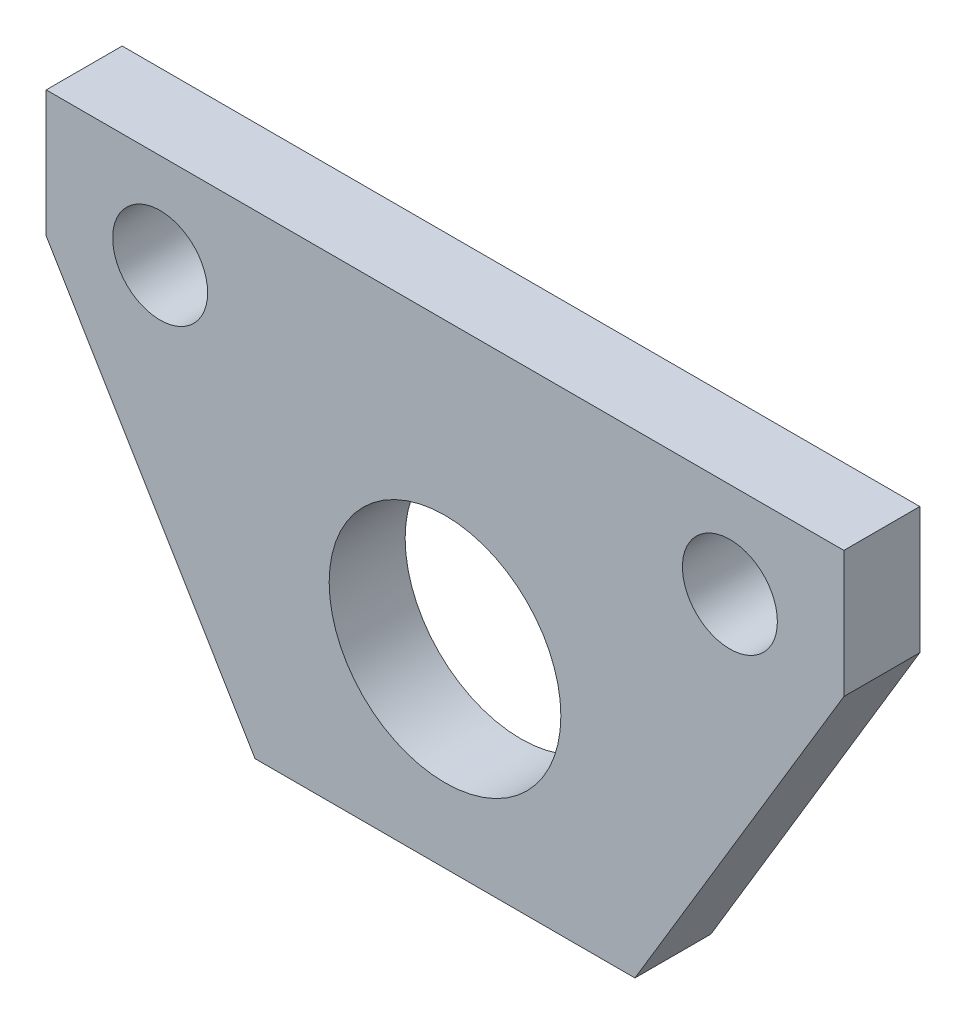
from build123d import *

# Parameters (mm, degrees)
BOSS_EXTRUDE1_DEPTH = 5.08
SKETCH3_R           = 7.747
SKETCH3_R_2         = 3.175
CUT_EXTRUDE2_DEPTH  = 5.08


with BuildPart() as part:
    # Sketch1 → Boss-Extrude1 (new body)
    with BuildSketch(Plane.XY):
        Polygon((-31.75, 31.75), (31.75, 31.75), (12.7, 0), (-12.7, 0), align=None)
    extrude(amount=BOSS_EXTRUDE1_DEPTH)

    # Sketch3 → Cut-Extrude2 (cut)
    with BuildSketch(Plane.XY.offset(5.08)):
        with Locations((0, 12.7)):
            Circle(SKETCH3_R)
        with Locations((-19.05, 25.4)):
            Circle(SKETCH3_R_2)
        with Locations((19.05, 25.4)):
            Circle(SKETCH3_R_2)
        Polygon((-26.67, 23.283333333), (-26.67, 31.75), (-31.75, 31.75), align=None)
        Polygon((26.67, 31.75), (26.67, 23.283333333), (31.75, 31.75), align=None)
    extrude(amount=-CUT_EXTRUDE2_DEPTH, mode=Mode.SUBTRACT)


solid = part.part
